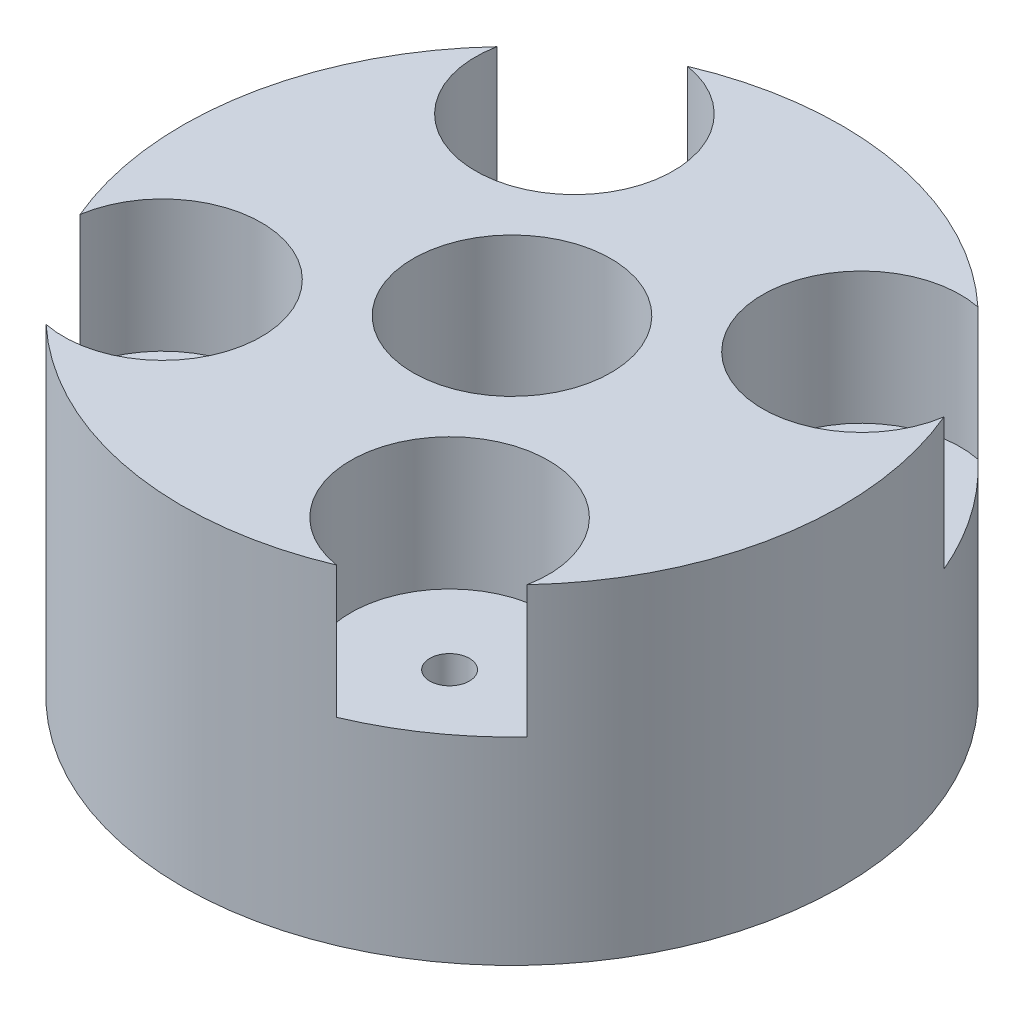
from build123d import *

# Parameters (mm, degrees)
CROQUIS1_R              = 10
SALIENTE_EXTRUIR1_DEPTH = 10
CORTAR_EXTRUIR1_DEPTH   = 5
CROQUIS3_R              = 0.6
CORTAR_EXTRUIR2_DEPTH   = 10
CROQUIS4_R              = 3
CORTAR_EXTRUIR3_DEPTH   = 5
CROQUIS5_R              = 3
CORTAR_EXTRUIR4_DEPTH   = 4


with BuildPart() as part:
    # Croquis1 → Saliente-Extruir1 (new body)
    with BuildSketch(Plane(origin=(0, 0, 0), x_dir=(1, 0, 0), z_dir=(0, 1, 0))):
        Circle(CROQUIS1_R)
    extrude(amount=SALIENTE_EXTRUIR1_DEPTH)

    # Croquis2 → Cortar-Extruir1 (cut)
    with BuildSketch(Plane.XZ):
        Polygon((5, 0), (2.5, 4.330127019), (-2.5, 4.330127019), (-5, 0), (-2.5, -4.330127019), (2.5, -4.330127019), align=None)
    extrude(amount=-CORTAR_EXTRUIR1_DEPTH, mode=Mode.SUBTRACT)

    # Croquis3 → Cortar-Extruir2 (cut)
    with BuildSketch(Plane.XZ):
        with Locations((-6.247955751, 4.354658302)):
            Circle(CROQUIS3_R)
        with Locations((6.247955751, -4.354658302)):
            Circle(CROQUIS3_R)
        with Locations((4.354658302, 6.247955751)):
            Circle(CROQUIS3_R)
        with Locations((-4.354658302, -6.247955751)):
            Circle(CROQUIS3_R)
    extrude(amount=-CORTAR_EXTRUIR2_DEPTH, mode=Mode.SUBTRACT)

    # Croquis4 → Cortar-Extruir3 (cut)
    with BuildSketch(Plane(origin=(0, 10, 0), x_dir=(1, 0, 0), z_dir=(0, 1, 0))):
        Circle(CROQUIS4_R)
    extrude(amount=-CORTAR_EXTRUIR3_DEPTH, mode=Mode.SUBTRACT)

    # Croquis5 → Cortar-Extruir4 (cut)
    with BuildSketch(Plane(origin=(0, 10, 0), x_dir=(1, 0, 0), z_dir=(0, 1, 0))):
        with Locations((6.247955751, 4.354658302)):
            Circle(CROQUIS5_R)
        with Locations((-4.354658302, 6.247955751)):
            Circle(CROQUIS5_R)
        with Locations((-6.247955751, -4.354658302)):
            Circle(CROQUIS5_R)
        with Locations((4.354658302, -6.247955751)):
            Circle(CROQUIS5_R)
    extrude(amount=-CORTAR_EXTRUIR4_DEPTH, mode=Mode.SUBTRACT)


solid = part.part
